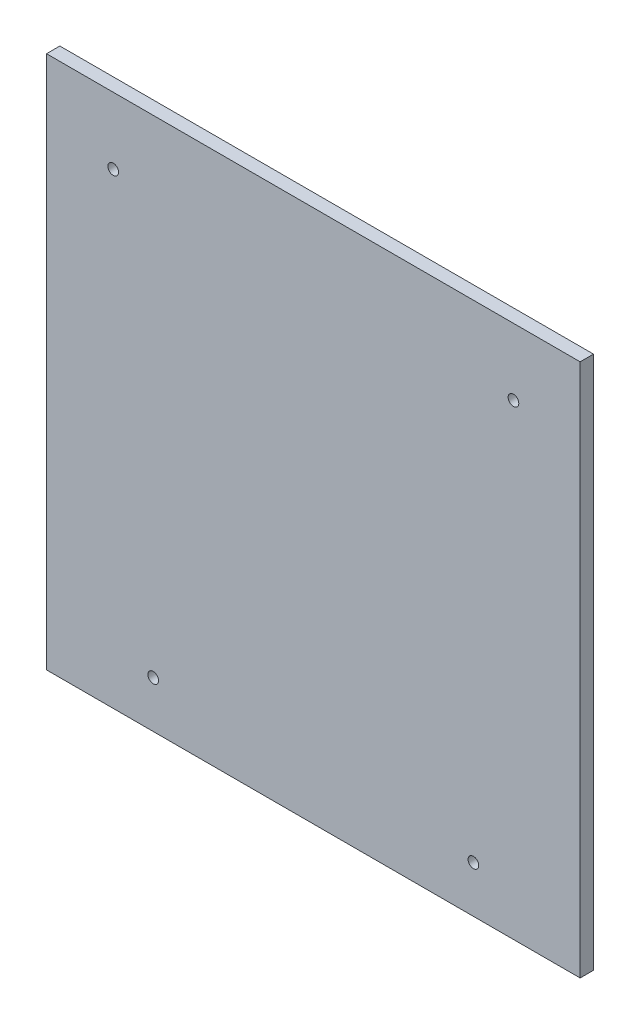
from build123d import *

# Parameters (mm, degrees)
SKETCH1_W           = 200
SKETCH1_H           = 200
SKETCH1_R           = 2
BOSS_EXTRUDE1_DEPTH = 5


with BuildPart() as part:
    # Sketch1 → Boss-Extrude1 (new body)
    with BuildSketch(Plane.XY):
        Rectangle(SKETCH1_W, SKETCH1_H)
        with Locations((-60, -82.5)):
            Circle(SKETCH1_R, mode=Mode.SUBTRACT)
        with Locations((-75, 75)):
            Circle(SKETCH1_R, mode=Mode.SUBTRACT)
        with Locations((60, -82.5)):
            Circle(SKETCH1_R, mode=Mode.SUBTRACT)
        with Locations((75, 75)):
            Circle(SKETCH1_R, mode=Mode.SUBTRACT)
    extrude(amount=BOSS_EXTRUDE1_DEPTH)


solid = part.part
